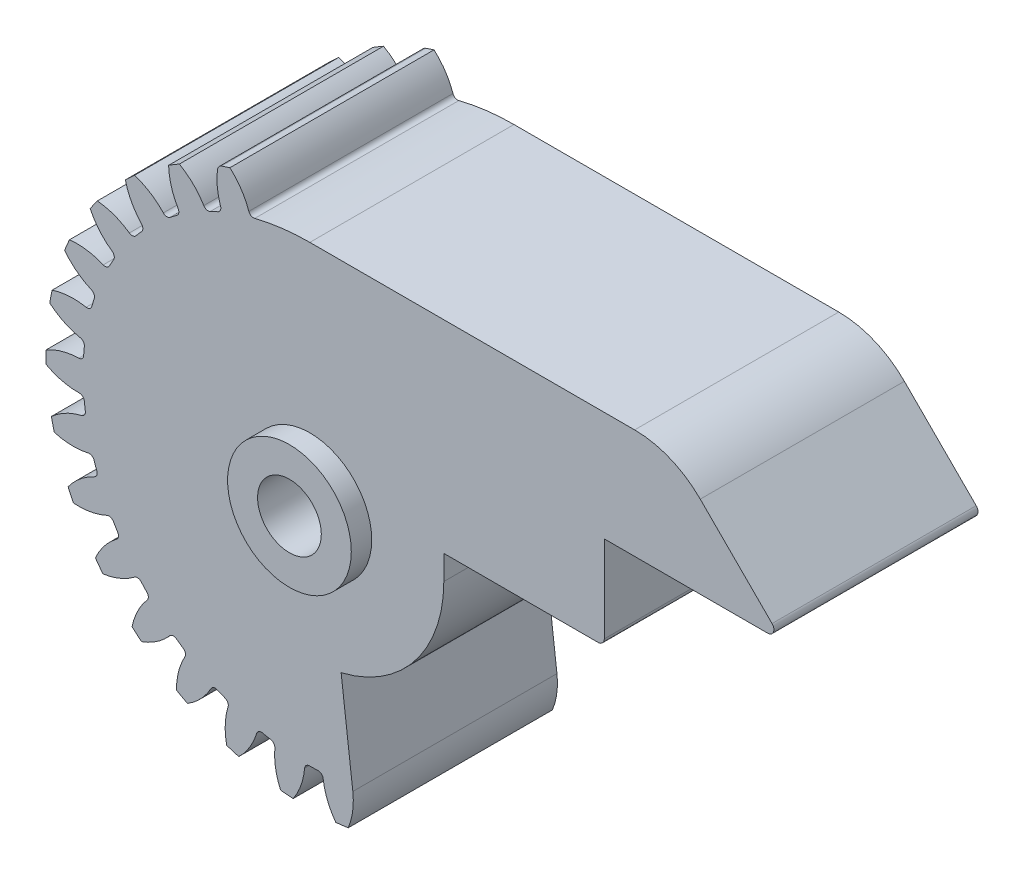
from build123d import *

# Parameters (mm, degrees)
SKBASE_R                                = 21.328
BASE_DEPTH                              = 8.25
TOOTHPROFILE_DEPTH                      = 9.25
FILLETTOOTHPROFILE_R                    = 0.3999
CIRPATTERNTEETH_COUNT                   = 30
FILLETTOOTHPROFILE_OF_CIRPATTERNTEETH_R = 0.3999
SKCHAVETA_R                             = 2.575
CHAVETA_DEPTH                           = 17.5000001
CUT_EXTRUDE1_DEPTH                      = 16.5
BODY_MOVE_COPY1_ANGLE                   = 1
BOSS_EXTRUDE1_DEPTH                     = 16.5
FILLET3_R                               = 0.5
BOSS_EXTRUDE2_START                     = -16.5
SKETCH10_R                              = 5
SKETCH10_R_2                            = 2.575
BOSS_EXTRUDE2_DEPTH                     = 1.65
FILLET4_R                               = 7.5
CHAMFER1_SIZE                           = 2
SKETCH11_W                              = 5.5
SKETCH11_H                              = 3
CUT_EXTRUDE2_DEPTH                      = 19.15
FILLET5_R                               = 0.5
CUT_EXTRUDE3_DEPTH                      = 19.15


with BuildPart() as part:
    # skBase → Base (new body, symmetric)
    with BuildSketch(Plane.XY):
        Circle(SKBASE_R)
    extrude(amount=BASE_DEPTH, both=True)

    # skToothProfile → ToothProfile (cut, symmetric)
    with BuildSketch(Plane.XY):
        with BuildLine():
            ThreePointArc((-0.721312484, 18.314551178), (-1.241450703, 20.43474689), (-2.550404893, 22.181862385))
            ThreePointArc((-2.550404893, 22.181862385), (0, 22.328), (2.550404893, 22.181862385))
            ThreePointArc((2.550404893, 22.181862385), (1.241450703, 20.43474689), (0.721312484, 18.314551178))
            ThreePointArc((0.721312484, 18.314551178), (0, 18.32875), (-0.721312484, 18.314551178))
        make_face()
    toothprofile = extrude(amount=TOOTHPROFILE_DEPTH, both=True, mode=Mode.SUBTRACT)

    # FilletToothProfile
    fillettoothprofile_edges = [part.edges().sort_by_distance(p)[0] for p in [
        (-0.721312484, 18.314551178, 0),
        (0.721312484, 18.314551178, 0),
    ]]
    fillet(fillettoothprofile_edges, radius=FILLETTOOTHPROFILE_R)

    # CirPatternTeeth: ToothProfile ×30 about axis
    cirpatternteeth_axis = Axis((0, 0, 0), (0, 0, 1))
    for i in range(1, CIRPATTERNTEETH_COUNT):
        add(toothprofile.rotate(cirpatternteeth_axis, i * 360 / CIRPATTERNTEETH_COUNT), mode=Mode.SUBTRACT)

    # FilletToothProfile of CirPatternTeeth
    fillettoothprofile_of_cirpatternteeth_edges = [part.edges().sort_by_distance(p)[0] for p in [
        (-4.513359377, 17.764364995, 0),
        (-3.102259227, 18.064303592, 0),
        (-8.108150809, 16.437790819, 0),
        (-6.790247323, 17.024559256, 0),
        (-11.348577143, 14.392806307, 0),
        (-10.181469027, 15.240759988, 0),
        (-14.093016199, 11.718787095, 0),
        (-13.127711679, 12.790866375, 0),
        (-16.221522821, 8.532600654, 0),
        (-15.500210337, 9.781950524, 0),
        (-17.641071057, 4.97349862, 0),
        (-17.195275425, 6.345516496, 0),
        (-18.289619836, 1.197030832, 0),
        (-18.138824465, 2.631752949, 0),
        (-18.138824465, -2.631752949, 0),
        (-18.289619836, -1.197030832, 0),
        (-17.195275425, -6.345516496, 0),
        (-17.641071057, -4.97349862, 0),
        (-15.500210337, -9.781950524, 0),
        (-16.221522821, -8.532600654, 0),
        (-13.127711679, -12.790866375, 0),
        (-14.093016199, -11.718787095, 0),
        (-10.181469027, -15.240759988, 0),
        (-11.348577143, -14.392806307, 0),
        (-6.790247323, -17.024559256, 0),
        (-8.108150809, -16.437790819, 0),
        (-3.102259227, -18.064303592, 0),
        (-4.513359377, -17.764364995, 0),
        (0.721312484, -18.314551178, 0),
        (-0.721312484, -18.314551178, 0),
        (4.513359377, -17.764364995, 0),
        (3.102259227, -18.064303592, 0),
        (8.108150809, -16.437790819, 0),
        (6.790247323, -17.024559256, 0),
        (11.348577143, -14.392806307, 0),
        (10.181469027, -15.240759988, 0),
        (14.093016199, -11.718787095, 0),
        (13.127711679, -12.790866375, 0),
        (16.221522821, -8.532600654, 0),
        (15.500210337, -9.781950524, 0),
        (17.641071057, -4.97349862, 0),
        (17.195275425, -6.345516496, 0),
        (18.289619836, -1.197030832, 0),
        (18.138824465, -2.631752949, 0),
        (18.138824465, 2.631752949, 0),
        (18.289619836, 1.197030832, 0),
        (17.195275425, 6.345516496, 0),
        (17.641071057, 4.97349862, 0),
        (15.500210337, 9.781950524, 0),
        (16.221522821, 8.532600654, 0),
        (13.127711679, 12.790866375, 0),
        (14.093016199, 11.718787095, 0),
        (10.181469027, 15.240759988, 0),
        (11.348577143, 14.392806307, 0),
        (6.790247323, 17.024559256, 0),
        (8.108150809, 16.437790819, 0),
        (3.102259227, 18.064303592, 0),
        (4.513359377, 17.764364995, 0),
    ]]
    fillet(fillettoothprofile_of_cirpatternteeth_edges, radius=FILLETTOOTHPROFILE_OF_CIRPATTERNTEETH_R)

    # skChaveta → Chaveta (cut, through all)
    with BuildSketch(Plane.XY.offset(8.25)):
        Circle(SKCHAVETA_R)
    extrude(amount=-CHAVETA_DEPTH, mode=Mode.SUBTRACT)

    # Sketch7 → Cut-Extrude1 (cut)
    with BuildSketch(Plane(origin=(0, 0, -8.25), x_dir=(-1, 0, 0), z_dir=(0, 0, -1))):
        with BuildLine():
            ThreePointArc((0.343190882, 18.325536734), (1.915876071, 18.22834319), (3.47440199, 17.996433185))
            ThreePointArc((3.47440199, 17.996433185), (3.229162978, 18.150648859), (3.152405176, 18.429992532))
            ThreePointArc((3.152405176, 18.429992532), (3.117768579, 19.817773482), (2.734370297, 21.151992887))
            ThreePointArc((2.734370297, 21.151992887), (2.229383065, 21.211162984), (1.723128859, 21.258278645))
            ThreePointArc((1.723128859, 21.258278645), (1.070708938, 20.03292812), (0.74829335, 18.682674866))
            ThreePointArc((0.74829335, 18.682674866), (0.615134075, 18.425394368), (0.343190882, 18.325536734))
        make_face()
        with BuildLine():
            ThreePointArc((-3.47440199, 17.996433185), (-1.915876071, 18.22834319), (-0.343190882, 18.325536734))
            ThreePointArc((-0.343190882, 18.325536734), (-0.615134075, 18.425394368), (-0.74829335, 18.682674866))
            ThreePointArc((-0.74829335, 18.682674866), (-1.070708938, 20.03292812), (-1.723128859, 21.258278645))
            ThreePointArc((-1.723128859, 21.258278645), (-2.229383065, 21.211162984), (-2.734370297, 21.151992887))
            ThreePointArc((-2.734370297, 21.151992887), (-3.117768579, 19.817773482), (-3.152405176, 18.429992532))
            ThreePointArc((-3.152405176, 18.429992532), (-3.229162978, 18.150648859), (-3.47440199, 17.996433185))
        make_face()
        with BuildLine():
            ThreePointArc((-7.140146823, 16.880799149), (-5.663895236, 17.431677123), (-4.145784665, 17.853726392))
            ThreePointArc((-4.145784665, 17.853726392), (-4.432546816, 17.894861728), (-4.616287865, 18.11883466))
            ThreePointArc((-4.616287865, 18.11883466), (-5.212391336, 19.372547671), (-6.105319016, 20.435475617))
            ThreePointArc((-6.105319016, 20.435475617), (-6.590714456, 20.28413338), (-7.072364351, 20.121263541))
            ThreePointArc((-7.072364351, 20.121263541), (-7.169984648, 18.736487047), (-6.915328468, 17.371831086))
            ThreePointArc((-6.915328468, 17.371831086), (-6.932330113, 17.082632899), (-7.140146823, 16.880799149))
        make_face()
        with BuildLine():
            ThreePointArc((-4.616287865, -18.11883466), (-4.432546816, -17.894861728), (-4.145784665, -17.853726392))
            ThreePointArc((-4.145784665, -17.853726392), (-5.663895236, -17.431677123), (-7.140146823, -16.880799149))
            ThreePointArc((-7.140146823, -16.880799149), (-6.932330113, -17.082632899), (-6.915328468, -17.371831086))
            ThreePointArc((-6.915328468, -17.371831086), (-7.169984648, -18.736487047), (-7.072364351, -20.121263541))
            ThreePointArc((-7.072364351, -20.121263541), (-6.590714456, -20.28413338), (-6.105319016, -20.435475617))
            ThreePointArc((-6.105319016, -20.435475617), (-5.212391336, -19.372547671), (-4.616287865, -18.11883466))
        make_face()
        with BuildLine():
            ThreePointArc((-10.493832977, 15.027393188), (-9.164375, 15.87316312), (-7.767187765, 16.601622535))
            ThreePointArc((-7.767187765, 16.601622535), (-8.056235993, 16.582237762), (-8.28252845, 16.763114436))
            ThreePointArc((-8.28252845, 16.763114436), (-9.126267221, 17.865493929), (-10.220677436, 18.719544245))
            ThreePointArc((-10.220677436, 18.719544245), (-10.664, 18.470589812), (-11.101262146, 18.211138426))
            ThreePointArc((-11.101262146, 18.211138426), (-10.908837983, 16.83632622), (-10.376018723, 15.554437263))
            ThreePointArc((-10.376018723, 15.554437263), (-10.332521157, 15.268023909), (-10.493832977, 15.027393188))
        make_face()
        with BuildLine():
            ThreePointArc((-8.28252845, -16.763114436), (-8.056235993, -16.582237762), (-7.767187765, -16.601622535))
            ThreePointArc((-7.767187765, -16.601622535), (-9.164375, -15.87316312), (-10.493832977, -15.027393188))
            ThreePointArc((-10.493832977, -15.027393188), (-10.332521157, -15.268023909), (-10.376018723, -15.554437263))
            ThreePointArc((-10.376018723, -15.554437263), (-10.908837983, -16.83632622), (-11.101262146, -18.211138426))
            ThreePointArc((-11.101262146, -18.211138426), (-10.664, -18.470589812), (-10.220677436, -18.719544245))
            ThreePointArc((-10.220677436, -18.719544245), (-9.126267221, -17.865493929), (-8.28252845, -16.763114436))
        make_face()
        with BuildLine():
            ThreePointArc((-13.388888275, 12.517218034), (-12.264327601, 13.62091572), (-11.049127488, 14.62394811))
            ThreePointArc((-11.049127488, 14.62394811), (-11.327828998, 14.544890435), (-11.586782797, 14.674765672))
            ThreePointArc((-11.586782797, 14.674765672), (-12.641281436, 15.577632373), (-13.889343207, 16.185478963))
            ThreePointArc((-13.889343207, 16.185478963), (-14.271217572, 15.849792838), (-14.644981515, 15.505099175))
            ThreePointArc((-14.644981515, 15.505099175), (-14.170922751, 14.200337147), (-13.38322717, 13.057239893))
            ThreePointArc((-13.38322717, 13.057239893), (-13.281131446, 12.786129011), (-13.388888275, 12.517218034))
        make_face()
        with BuildLine():
            ThreePointArc((-11.586782797, -14.674765672), (-11.327828998, -14.544890435), (-11.049127488, -14.62394811))
            ThreePointArc((-11.049127488, -14.62394811), (-12.264327601, -13.62091572), (-13.388888275, -12.517218034))
            ThreePointArc((-13.388888275, -12.517218034), (-13.281131446, -12.786129011), (-13.38322717, -13.057239893))
            ThreePointArc((-13.38322717, -13.057239893), (-14.170922751, -14.200337147), (-14.644981515, -15.505099175))
            ThreePointArc((-14.644981515, -15.505099175), (-14.271217572, -15.849792838), (-13.889343207, -16.185478963))
            ThreePointArc((-13.889343207, -16.185478963), (-12.641281436, -15.577632373), (-11.586782797, -14.674765672))
        make_face()
        with BuildLine():
            ThreePointArc((-15.698784909, 9.459980389), (-14.828270236, 10.773368943), (-13.848167321, 12.007136979))
            ThreePointArc((-13.848167321, 12.007136979), (-14.104341519, 11.871861601), (-14.384639136, 11.945059231))
            ThreePointArc((-14.384639136, 11.945059231), (-15.603810993, 12.608953534), (-16.950978032, 12.944030584))
            ThreePointArc((-16.950978032, 12.944030584), (-17.254714456, 12.536283861), (-17.548644917, 12.121412689))
            ThreePointArc((-17.548644917, 12.121412689), (-16.813670196, 10.9437252), (-15.80552437, 9.989378484))
            ThreePointArc((-15.80552437, 9.989378484), (-15.64929256, 9.74541892), (-15.698784909, 9.459980389))
        make_face()
        with BuildLine():
            ThreePointArc((-14.384639136, -11.945059231), (-14.104341519, -11.871861601), (-13.848167321, -12.007136979))
            ThreePointArc((-13.848167321, -12.007136979), (-14.828270236, -10.773368943), (-15.698784909, -9.459980389))
            ThreePointArc((-15.698784909, -9.459980389), (-15.64929256, -9.74541892), (-15.80552437, -9.989378484))
            ThreePointArc((-15.80552437, -9.989378484), (-16.813670196, -10.9437252), (-17.548644917, -12.121412689))
            ThreePointArc((-17.548644917, -12.121412689), (-17.254714456, -12.536283861), (-16.950978032, -12.944030584))
            ThreePointArc((-16.950978032, -12.944030584), (-15.603810993, -12.608953534), (-14.384639136, -11.945059231))
        make_face()
        with BuildLine():
            ThreePointArc((-17.322569311, 5.989296206), (-16.744146307, 7.454974247), (-16.04197579, 8.865556345))
            ThreePointArc((-16.04197579, 8.865556345), (-16.264426635, 8.679975449), (-16.55381772, 8.693296383))
            ThreePointArc((-16.55381772, 8.693296383), (-17.884379133, 9.08920292), (-19.271773777, 9.136865956))
            ThreePointArc((-19.271773777, 9.136865956), (-19.484097521, 8.674879124), (-19.685348329, 8.207962303))
            ThreePointArc((-19.685348329, 8.207962303), (-18.721579572, 7.208819949), (-17.537044312, 6.484933301))
            ThreePointArc((-17.537044312, 6.484933301), (-17.333504496, 6.278787258), (-17.322569311, 5.989296206))
        make_face()
        with BuildLine():
            ThreePointArc((-16.55381772, -8.693296383), (-16.264426635, -8.679975449), (-16.04197579, -8.865556345))
            ThreePointArc((-16.04197579, -8.865556345), (-16.744146307, -7.454974247), (-17.322569311, -5.989296206))
            ThreePointArc((-17.322569311, -5.989296206), (-17.333504496, -6.278787258), (-17.537044312, -6.484933301))
            ThreePointArc((-17.537044312, -6.484933301), (-18.721579572, -7.208819949), (-19.685348329, -8.207962303))
            ThreePointArc((-19.685348329, -8.207962303), (-19.484097521, -8.674879124), (-19.271773777, -9.136865956))
            ThreePointArc((-19.271773777, -9.136865956), (-17.884379133, -9.08920292), (-16.55381772, -8.693296383))
        make_face()
        with BuildLine():
            ThreePointArc((-18.189274311, 2.256851039), (-17.928222837, 3.810761403), (-17.53467294, 5.336508357))
            ThreePointArc((-17.53467294, 5.336508357), (-17.713678262, 5.108732718), (-17.999515036, 5.061594767))
            ThreePointArc((-17.999515036, 5.061594767), (-19.383314087, 5.172210524), (-20.750300531, 4.930376442))
            ThreePointArc((-20.750300531, 4.930376442), (-20.861932028, 4.434340542), (-20.961707558, 3.935784578))
            ThreePointArc((-20.961707558, 3.935784578), (-19.811266084, 3.158854673), (-18.502111265, 2.697065414))
            ThreePointArc((-18.502111265, 2.697065414), (-18.26015911, 2.537742464), (-18.189274311, 2.256851039))
        make_face()
        with BuildLine():
            ThreePointArc((-17.999515036, -5.061594767), (-17.713678262, -5.108732718), (-17.53467294, -5.336508357))
            ThreePointArc((-17.53467294, -5.336508357), (-17.928222837, -3.810761403), (-18.189274311, -2.256851039))
            ThreePointArc((-18.189274311, -2.256851039), (-18.26015911, -2.537742464), (-18.502111265, -2.697065414))
            ThreePointArc((-18.502111265, -2.697065414), (-19.811266084, -3.158854673), (-20.961707558, -3.935784578))
            ThreePointArc((-20.961707558, -3.935784578), (-20.861932028, -4.434340542), (-20.750300531, -4.930376442))
            ThreePointArc((-20.750300531, -4.930376442), (-19.383314087, -5.172210524), (-17.999515036, -5.061594767))
        make_face()
        with BuildLine():
            ThreePointArc((-18.261020742, -1.574229347), (-18.32875, 0), (-18.261020742, 1.574229347))
            ThreePointArc((-18.261020742, 1.574229347), (-18.388757149, 1.314213852), (-18.658547173, 1.208677173))
            ThreePointArc((-18.658547173, 1.208677173), (-20.035105204, 1.029167709), (-21.321939582, 0.508405819))
            ThreePointArc((-21.321939582, 0.508405819), (-21.328, 0), (-21.321939582, -0.508405819))
            ThreePointArc((-21.321939582, -0.508405819), (-20.035105204, -1.029167709), (-18.658547173, -1.208677173))
            ThreePointArc((-18.658547173, -1.208677173), (-18.388757149, -1.314213852), (-18.261020742, -1.574229347))
        make_face()
    extrude(amount=-CUT_EXTRUDE1_DEPTH, mode=Mode.SUBTRACT)


with BuildPart() as part_1:
    # Body-Move/Copy1: moved
    add(part.part.rotate(Axis((-1.499625, -0.411401514, 0), (0, 0, 1)), BODY_MOVE_COPY1_ANGLE))

    # Sketch9 → Boss-Extrude1 (add)
    with BuildSketch(Plane(origin=(0, 0, -8.25), x_dir=(-1, 0, 0), z_dir=(0, 0, -1))):
        with BuildLine():
            Line((-38.207403537, 9.5), (-23.792596463, 9.5))
            Line((-23.792596463, 9.5), (-23.792596463, -1))
            Line((-23.792596463, -1), (-18.292596463, -1))
            ThreePointArc((-18.292596463, -1), (-13.310819376, 12.618483563), (0.007408347, 18.354859407))
            Line((0.007408347, 18.354859407), (-29.35254413, 18.354859407))
            Line((-29.35254413, 18.354859407), (-38.207403537, 9.5))
        make_face()
    extrude(amount=-BOSS_EXTRUDE1_DEPTH)

    # Fillet3
    fillet3_edges = [part_1.edges().sort_by_distance(p)[0] for p in [
        (38.207403537, 9.5, 0),
        (-7.429860012, 20.020878605, 0),
    ]]
    fillet(fillet3_edges, radius=FILLET3_R)

    # Sketch10 → Boss-Extrude2 (add)
    with BuildSketch(Plane(origin=(0, 0, -8.25), x_dir=(-1, 0, 0), z_dir=(0, 0, -1)).offset(BOSS_EXTRUDE2_START)):
        with Locations((0.007408347, 0.026109407)):
            Circle(SKETCH10_R)
        with Locations((0.007408347, 0.026109407)):
            Circle(SKETCH10_R_2, mode=Mode.SUBTRACT)
    extrude(amount=-BOSS_EXTRUDE2_DEPTH)

    # Fillet4
    fillet4_edges = [part_1.edges().sort_by_distance(p)[0] for p in [
        (29.35254413, 18.354859407, 0),
    ]]
    fillet(fillet4_edges, radius=FILLET4_R)

    # Chamfer1
    chamfer1_edges = [part_1.edges().sort_by_distance(p)[0] for p in [
        (23.792596463, -1, 0),
    ]]
    chamfer(chamfer1_edges, length=CHAMFER1_SIZE)

    # Sketch11 → Cut-Extrude2 (cut, through all)
    with BuildSketch(Plane(origin=(0, 0, -8.25), x_dir=(-1, 0, 0), z_dir=(0, 0, -1))):
        with Locations((-21.042596463, 0.5)):
            Rectangle(SKETCH11_W, SKETCH11_H)
    extrude(amount=-CUT_EXTRUDE2_DEPTH, mode=Mode.SUBTRACT)

    # Fillet5
    fillet5_edges = [part_1.edges().sort_by_distance(p)[0] for p in [
        (23.792596463, 2, 0),
    ]]
    fillet(fillet5_edges, radius=FILLET5_R)

    # Sketch12 → Cut-Extrude3 (cut, through all)
    with BuildSketch(Plane(origin=(0, 0, -8.25), x_dir=(-1, 0, 0), z_dir=(0, 0, -1))):
        with BuildLine():
            Line((-18.292596463, 2), (-10.821341653, 2))
            Line((-10.821341653, 2), (-10.821341653, 0.026109407))
            ThreePointArc((-10.821341653, 0.026109407), (-8.496755611, -6.67769712), (-2.52102593, -10.503318245))
            Line((-2.52102593, -10.503318245), (-3.466164423, -18.346059091))
            ThreePointArc((-3.466164423, -18.346059091), (-3.538035315, -18.065418356), (-3.780545541, -17.906946159))
            ThreePointArc((-3.780545541, -17.906946159), (-13.900527768, -11.911745912), (-18.292596463, -1))
            Line((-18.292596463, -1), (-18.292596463, 2))
        make_face()
    extrude(amount=-CUT_EXTRUDE3_DEPTH, mode=Mode.SUBTRACT)


solid = part_1.part
